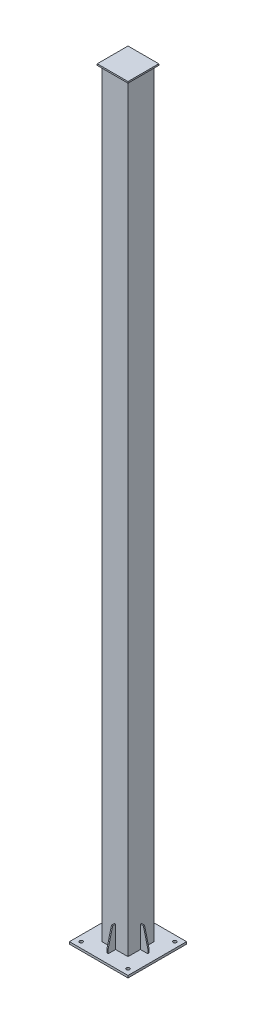
from build123d import *

# Parameters (mm, degrees)
SKETCH1_W           = 177.8
SKETCH1_H           = 177.8
SKETCH1_W_2         = 167.8
SKETCH1_H_2         = 167.8
BOSS_EXTRUDE1_DEPTH = 5181.6
SKETCH4_W           = 210
SKETCH4_H           = 210
BOSS_EXTRUDE3_DEPTH = 10
SKETCH6_W           = 400
SKETCH6_H           = 400
SKETCH6_R           = 11
SKETCH6_R_2         = 10
BOSS_EXTRUDE4_DEPTH = 15
BOSS_EXTRUDE5_DEPTH = 4
CIRPATTERN1_COUNT   = 4


with BuildPart() as part:
    # Sketch1 → Boss-Extrude1 (new body)
    with BuildSketch(Plane.XZ):
        Rectangle(SKETCH1_W, SKETCH1_H)
        Rectangle(SKETCH1_W_2, SKETCH1_H_2, mode=Mode.SUBTRACT)
    extrude(amount=BOSS_EXTRUDE1_DEPTH)

    # Sketch4 → Boss-Extrude3 (add)
    with BuildSketch(Plane(origin=(0, 0, 0), x_dir=(1, 0, 0), z_dir=(0, 1, 0))):
        Rectangle(SKETCH4_W, SKETCH4_H)
    extrude(amount=BOSS_EXTRUDE3_DEPTH)

    # Sketch6 → Boss-Extrude4 (add)
    with BuildSketch(Plane.XZ.offset(5181.6)):
        Rectangle(SKETCH6_W, SKETCH6_H)
        with Locations((-160, 160)):
            Circle(SKETCH6_R, mode=Mode.SUBTRACT)
        with Locations((160, 160)):
            Circle(SKETCH6_R, mode=Mode.SUBTRACT)
        with Locations((160, -160)):
            Circle(SKETCH6_R, mode=Mode.SUBTRACT)
        with Locations((-160, -160)):
            Circle(SKETCH6_R, mode=Mode.SUBTRACT)
        Circle(SKETCH6_R_2, mode=Mode.SUBTRACT)
    extrude(amount=BOSS_EXTRUDE4_DEPTH)


with BuildPart() as body_2:
    # Sketch7 → Boss-Extrude5 (new, symmetric)
    with BuildSketch(Plane(origin=(0, 0, 0), x_dir=(0, 0, -1), z_dir=(1, 0, 0))):
        Polygon((88.9, -5031.6), (108.9, -5031.6), (138.9, -5151.6), (138.9, -5181.6), (88.9, -5181.6), align=None)
    extrude(amount=BOSS_EXTRUDE5_DEPTH, both=True)


with BuildPart() as cirpattern1_1:
    # CirPattern1: pattern copy
    add(body_2.part.rotate(Axis((0, 214.45, 0), (0, -1, 0)), 1 * 360 / CIRPATTERN1_COUNT))


with BuildPart() as cirpattern1_2:
    # CirPattern1: pattern copy
    add(body_2.part.rotate(Axis((0, 214.45, 0), (0, -1, 0)), 2 * 360 / CIRPATTERN1_COUNT))


with BuildPart() as cirpattern1_3:
    # CirPattern1: pattern copy
    add(body_2.part.rotate(Axis((0, 214.45, 0), (0, -1, 0)), 3 * 360 / CIRPATTERN1_COUNT))


solid = Compound([part.part, body_2.part, cirpattern1_1.part, cirpattern1_2.part, cirpattern1_3.part])
